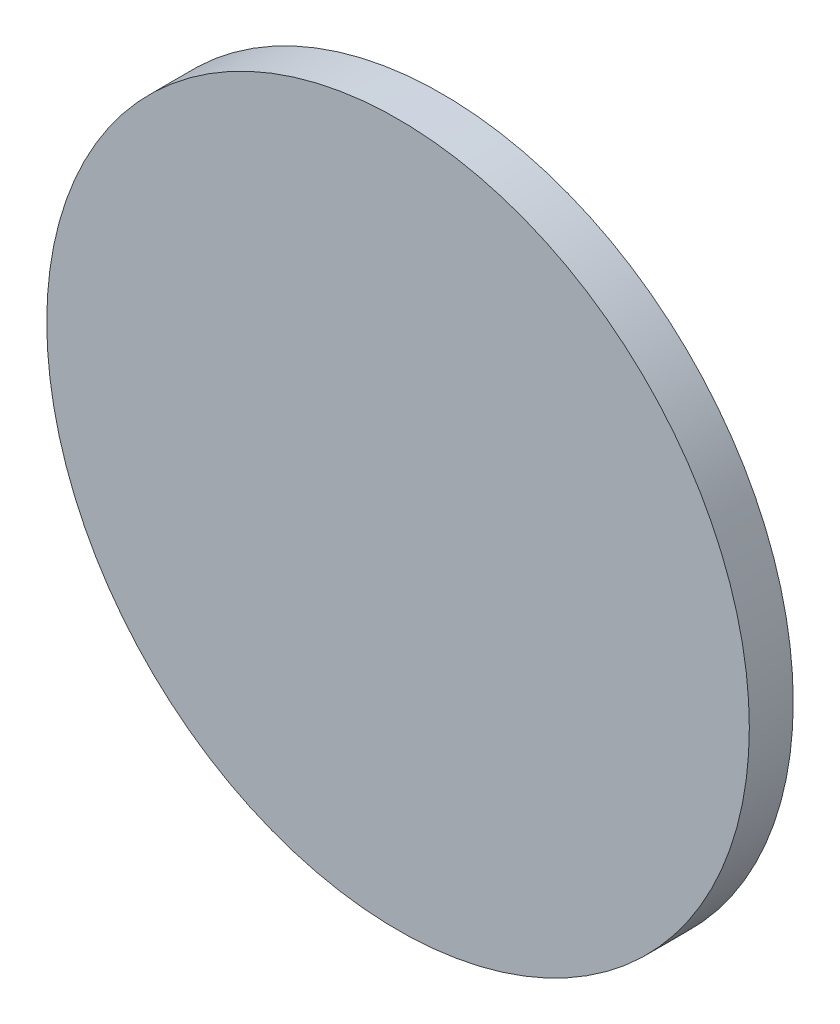
from build123d import *

# Parameters (mm, degrees)
SKETCH2_R           = 25.4
BOSS_EXTRUDE1_DEPTH = 3.175


with BuildPart() as part:
    # Sketch2 → Boss-Extrude1 (new body)
    with BuildSketch(Plane.XY):
        Circle(SKETCH2_R)
    extrude(amount=BOSS_EXTRUDE1_DEPTH)


solid = part.part
